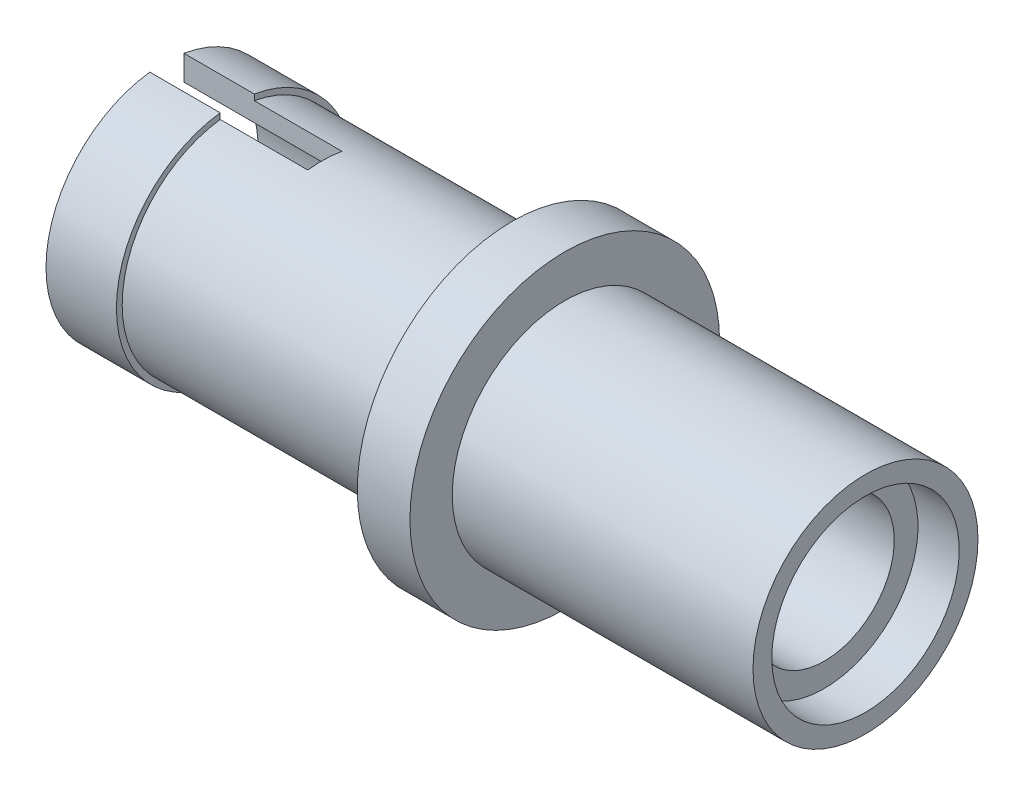
from build123d import *

# Parameters (mm, degrees)
CUT_EXTRUDE1_DEPTH = 5.08


with BuildPart() as part:
    # Sketch1 → Revolve3 (revolve)
    with BuildSketch(Plane.XY):
        Polygon((-64.046377149, 7.114962412), (-57.649439031, 7.114962412), (-57.649439031, 6.352962412), (-52.863745559, 6.352962412), (-52.863745559, 4.101714874), (-51.170838104, 4.101714874), (-51.170838104, 6.352962412), (-42.828401085, 6.352962412), (-42.828401085, 7.114962412), (-41.502858565, 7.114962412), (-41.502858565, 7.718234779), (-51.170838104, 7.718234779), (-51.170838104, 9.078659997), (-52.863745559, 9.078659997), (-52.863745559, 7.718234779), (-54.862931861, 7.718234779), (-55.961416497, 7.718234779), (-58.85700077, 7.718234779), (-59.483688957, 7.718234779), (-61.781937161, 7.718234779), (-61.781937161, 7.902812446), (-64.046377149, 7.902812446), align=None)
    revolve(axis=Axis((-52.863745559, 4.101714874, 0), (1, 0, 0)))

    # Sketch4 → Cut-Extrude1 (cut)
    with BuildSketch(Plane.ZY.offset(64.046377149)):
        Polygon((-0.631646969, 7.849963113), (-0.631646969, 8.219502832), (0.464537278, 8.219502832), (0.464537278, 7.849963113), (0.464537278, 0.329109955), (-0.370144054, 0), (-0.631646969, 0.329109955), align=None)
    extrude(amount=-CUT_EXTRUDE1_DEPTH, mode=Mode.SUBTRACT)


solid = part.part
